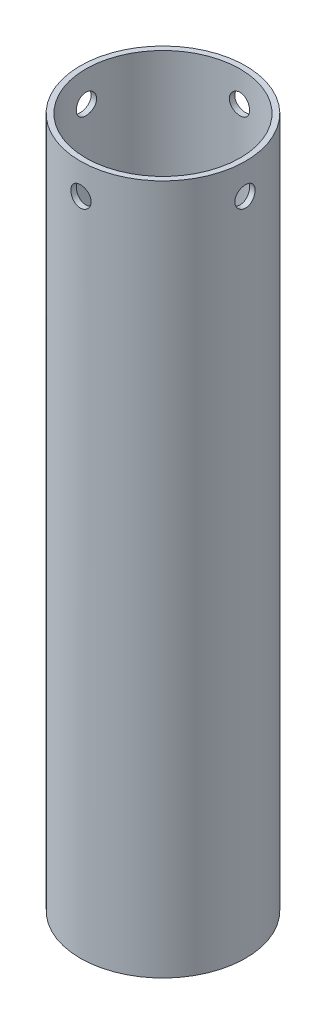
from build123d import *

# Parameters (mm, degrees)
SKIZZE1_R                            = 20.35
SKIZZE1_R_2                          = 19
AUFSATZ_LINEAR_AUSTRAGEN1_DEPTH      = 170
SKIZZE2_R                            = 2.5
SCHNITT_LINEAR_AUSTRAGEN1_DEPTH      = 21.35
SCHNITT_LINEAR_AUSTRAGEN1_DEPTH_BACK = 21.35
SKIZZE3_R                            = 2.5
SCHNITT_LINEAR_AUSTRAGEN2_DEPTH      = 21.3500001
SCHNITT_LINEAR_AUSTRAGEN2_DEPTH_BACK = 21.3500001


with BuildPart() as part:
    # Skizze1 → Aufsatz-Linear austragen1 (new body)
    with BuildSketch(Plane(origin=(0, 0, 0), x_dir=(1, 0, 0), z_dir=(0, 1, 0))):
        Circle(SKIZZE1_R)
        Circle(SKIZZE1_R_2, mode=Mode.SUBTRACT)
    extrude(amount=AUFSATZ_LINEAR_AUSTRAGEN1_DEPTH)

    # Skizze2 → Schnitt-Linear austragen1 (cut, two sides)
    with BuildSketch(Plane.XY) as schnitt_linear_austragen1_sk:
        with Locations((0, 162.5)):
            Circle(SKIZZE2_R)
    extrude(amount=SCHNITT_LINEAR_AUSTRAGEN1_DEPTH, mode=Mode.SUBTRACT)
    extrude(schnitt_linear_austragen1_sk.sketch, amount=-SCHNITT_LINEAR_AUSTRAGEN1_DEPTH_BACK, mode=Mode.SUBTRACT)

    # Skizze3 → Schnitt-Linear austragen2 (cut, two sides)
    with BuildSketch(Plane(origin=(0, 0, 0), x_dir=(0, 0, -1), z_dir=(1, 0, 0))) as schnitt_linear_austragen2_sk:
        with Locations((0, 162.5)):
            Circle(SKIZZE3_R)
    extrude(amount=SCHNITT_LINEAR_AUSTRAGEN2_DEPTH, mode=Mode.SUBTRACT)
    extrude(schnitt_linear_austragen2_sk.sketch, amount=-SCHNITT_LINEAR_AUSTRAGEN2_DEPTH_BACK, mode=Mode.SUBTRACT)


solid = part.part
